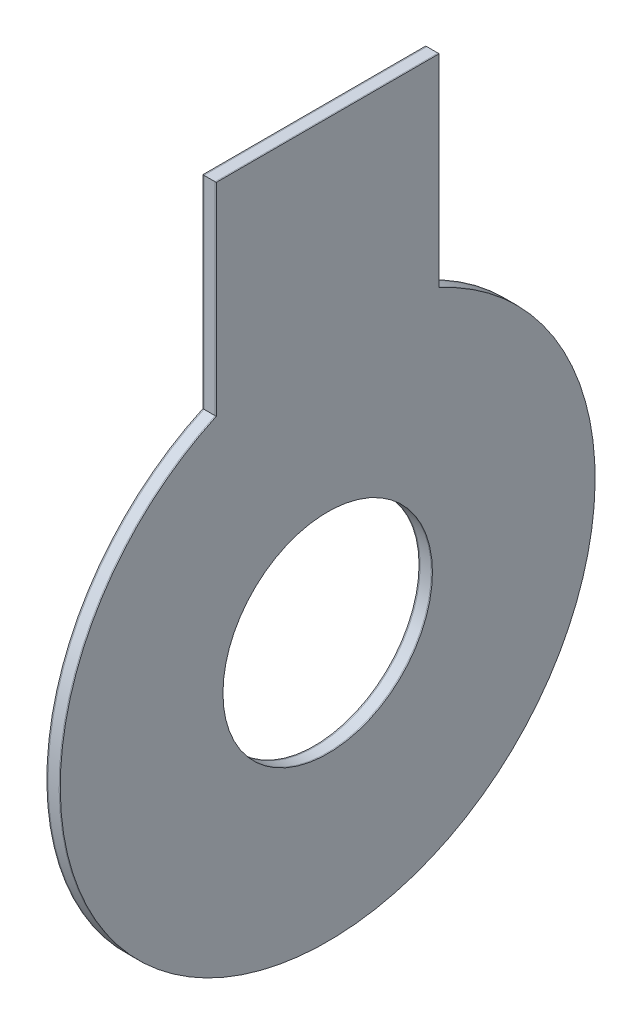
from build123d import *

# Parameters (mm, degrees)
SKETCH1_R           = 60
SKETCH1_R_2         = 23.5
BOSS_EXTRUDE1_DEPTH = 0.25
SKETCH4_R           = 23.5
BOSS_EXTRUDE4_DEPTH = 2.5
SKETCH5_R           = 23.5
BOSS_EXTRUDE5_DEPTH = 0.25


with BuildPart() as part:
    # Sketch1 → Boss-Extrude1 (new body)
    with BuildSketch(Plane(origin=(0, 0, 0), x_dir=(0, 0, -1), z_dir=(1, 0, 0))):
        with BuildLine():
            Line((25, 100), (-25, 100))
            Line((-25, 100), (-25, 54.543560573))
            ThreePointArc((-25, 54.543560573), (0, 60), (25, 54.543560573))
            Line((25, 54.543560573), (25, 100))
        make_face()
        Circle(SKETCH1_R)
        Circle(SKETCH1_R_2, mode=Mode.SUBTRACT)
    extrude(amount=BOSS_EXTRUDE1_DEPTH)


with BuildPart() as body_2:
    # Sketch4 → Boss-Extrude4 (new body)
    with BuildSketch(Plane.ZY):
        with BuildLine():
            Line((25, 54.543560573), (25, 100))
            Line((25, 100), (-25, 100))
            Line((-25, 100), (-25, 54.543560573))
            ThreePointArc((-25, 54.543560573), (0, -60), (25, 54.543560573))
        make_face()
        Circle(SKETCH4_R, mode=Mode.SUBTRACT)
    extrude(amount=BOSS_EXTRUDE4_DEPTH)


with BuildPart() as body_3:
    # Sketch5 → Boss-Extrude5 (new body)
    with BuildSketch(Plane.ZY.offset(2.5)):
        with BuildLine():
            Line((25, 54.543560573), (25, 100))
            Line((25, 100), (-25, 100))
            Line((-25, 100), (-25, 54.543560573))
            ThreePointArc((-25, 54.543560573), (0, -60), (25, 54.543560573))
        make_face()
        Circle(SKETCH5_R, mode=Mode.SUBTRACT)
    extrude(amount=BOSS_EXTRUDE5_DEPTH)


solid = Compound([part.part, body_2.part, body_3.part])
